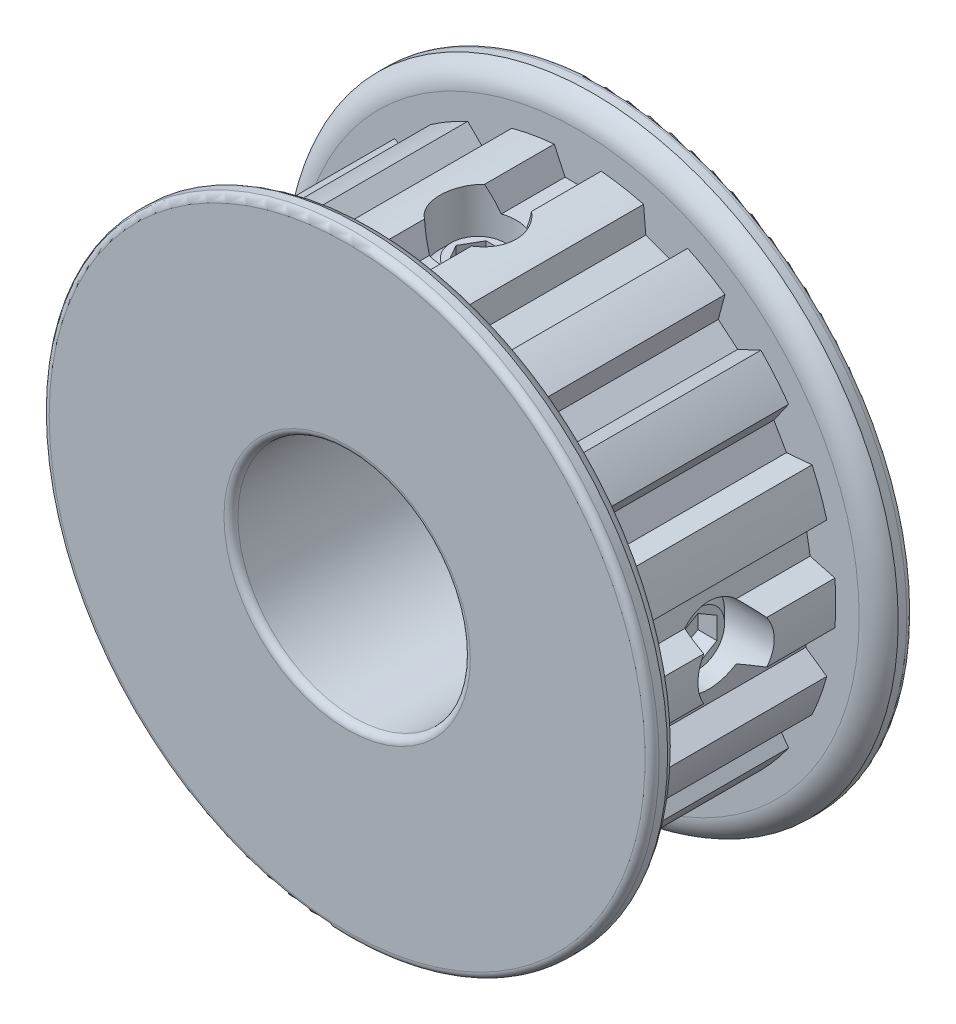
from build123d import *

# Parameters (mm, degrees)
CUT_EXTRUDE1_START = 5.4483
CUT_EXTRUDE1_DEPTH = 10.8966
CIRPATTERN1_COUNT  = 18
FILLET1_R          = 0.381
SKETCH5_R          = 2.0828
CUT_EXTRUDE2_DEPTH = 25.625090571
CUT_EXTRUDE3_DEPTH = 1.0414
CIRPATTERN2_COUNT  = 2
CIRPATTERN2_ANGLE  = 270


with BuildPart() as part:
    # Sketch2 → Revolve1 (revolve)
    with BuildSketch(Plane(origin=(0, 0, 0), x_dir=(0, 0, -1), z_dir=(1, 0, 0)), mode=Mode.PRIVATE) as revolve1_sk:
        with BuildLine():
            Line((-7.1501, 6.35), (7.1501, 6.35))
            Line((7.1501, 6.35), (7.1501, 16.6624))
            Line((7.1501, 16.6624), (6.2992, 16.6624))
            ThreePointArc((6.2992, 16.6624), (5.680462063, 16.151565665), (5.4483, 15.383523265))
            Line((5.4483, 15.383523265), (5.4483, 14.10464653))
            Line((5.4483, 14.10464653), (-5.4483, 14.10464653))
            Line((-5.4483, 14.10464653), (-5.4483, 15.383523265))
            ThreePointArc((-5.4483, 15.383523265), (-5.680462063, 16.151565665), (-6.2992, 16.6624))
            Line((-6.2992, 16.6624), (-7.1501, 16.6624))
            Line((-7.1501, 16.6624), (-7.1501, 6.35))
        make_face()
    revolve(revolve1_sk.sketch.rotate(Axis((0, 0, 7.1501), (0, 0, -1)), 90), axis=Axis((0, 0, 7.1501), (0, 0, -1)))

    # Sketch3 → Cut-Extrude1 (cut)
    with BuildSketch(Plane.XY.offset(CUT_EXTRUDE1_START)):
        with BuildLine():
            Line((-0.690489274, 12.7762), (0.690489274, 12.7762))
            Line((0.690489274, 12.7762), (1.2827, 14.0462))
            ThreePointArc((1.2827, 14.0462), (0, 14.10464653), (-1.2827, 14.0462))
            Line((-1.2827, 14.0462), (-0.690489274, 12.7762))
        make_face()
    cut_extrude1 = extrude(amount=-CUT_EXTRUDE1_DEPTH, mode=Mode.SUBTRACT)

    # CirPattern1: Cut-Extrude1 ×18 about axis
    cirpattern1_axis = Axis((0, 0, 0), (0, 0, 1))
    for i in range(1, CIRPATTERN1_COUNT):
        add(cut_extrude1.rotate(cirpattern1_axis, i * 360 / CIRPATTERN1_COUNT), mode=Mode.SUBTRACT)

    # Fillet1
    fillet1_edges = [part.edges().sort_by_distance(p)[0] for p in [
        (-16.6624, 0, -7.1501),
        (-6.35, 0, -7.1501),
        (-6.35, 0, 7.1501),
        (-16.6624, 0, 7.1501),
    ]]
    fillet(fillet1_edges, radius=FILLET1_R)

    # Sketch5 → Cut-Extrude2 (cut, through all)
    with BuildSketch(Plane(origin=(0, 0, 0), x_dir=(1, 0, 0), z_dir=(0, 1, 0))):
        with Locations(Location((0, 0, 0), (0, 0, 90))):
            Circle(SKETCH5_R)
    cut_extrude2 = extrude(amount=CUT_EXTRUDE2_DEPTH, mode=Mode.SUBTRACT)

    # Sketch6 → Revolve2 (revolve)
    with BuildSketch(Plane(origin=(0, 0, 0), x_dir=(0, 0, -1), z_dir=(1, 0, 0)), mode=Mode.PRIVATE) as revolve2_sk:
        Polygon((0, 12.0142), (0, 7.112), (-1.45796, 7.112), (-2.0828, 7.73684), (-2.0828, 11.38936), (-1.45796, 12.0142), align=None)
    revolve2 = revolve(revolve2_sk.sketch.rotate(Axis((0, 12.0142, 0), (0, -1, 0)), 180), axis=Axis((0, 12.0142, 0), (0, -1, 0)))

    # Sketch7 → Cut-Extrude3 (cut)
    with BuildSketch(Plane(origin=(0, 12.0142, 0), x_dir=(1, 0, 0), z_dir=(0, 1, 0))):
        Polygon((1.202505141, 0), (0.60125257, 1.0414), (-0.60125257, 1.0414), (-1.202505141, 0), (-0.60125257, -1.0414), (0.60125257, -1.0414), align=None)
    cut_extrude3 = extrude(amount=-CUT_EXTRUDE3_DEPTH, mode=Mode.SUBTRACT)

    # CirPattern2: Cut-Extrude2, Revolve2, Cut-Extrude3 ×2 about axis
    cirpattern2_axis = Axis((0, 0, 0), (0, 0, 1))
    add([cut_extrude2.rotate(cirpattern2_axis, i * CIRPATTERN2_ANGLE / (CIRPATTERN2_COUNT - 1)) for i in range(1, CIRPATTERN2_COUNT)], mode=Mode.SUBTRACT)
    add([revolve2.rotate(cirpattern2_axis, i * CIRPATTERN2_ANGLE / (CIRPATTERN2_COUNT - 1)) for i in range(1, CIRPATTERN2_COUNT)])
    add([cut_extrude3.rotate(cirpattern2_axis, i * CIRPATTERN2_ANGLE / (CIRPATTERN2_COUNT - 1)) for i in range(1, CIRPATTERN2_COUNT)], mode=Mode.SUBTRACT)


solid = part.part
